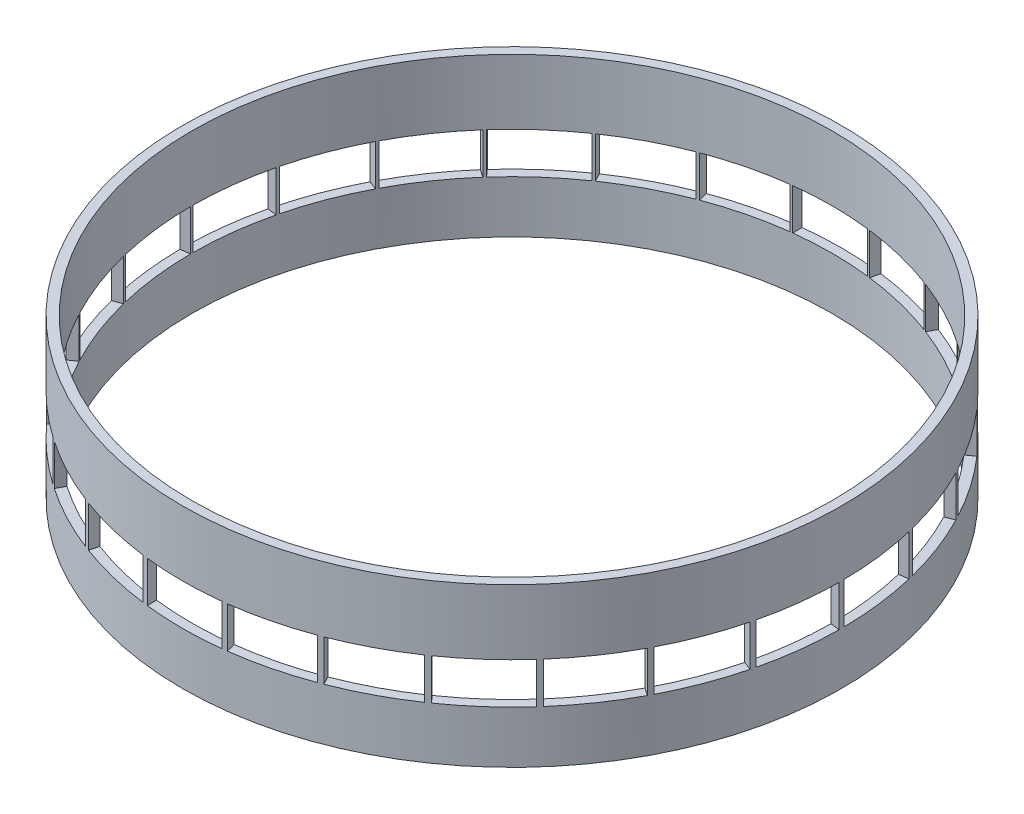
from build123d import *

# Parameters (mm, degrees)
SKETCH1_R           = 88.365
SKETCH1_R_2         = 85.865
BOSS_EXTRUDE1_DEPTH = 42.425
SKETCH2_W           = 20
SKETCH2_H           = 11
CUT_EXTRUDE1_DEPTH  = 89.365
CIRPATTERN1_COUNT   = 13


with BuildPart() as part:
    # Sketch1 → Boss-Extrude1 (new body)
    with BuildSketch(Plane(origin=(0, 0, 0), x_dir=(1, 0, 0), z_dir=(0, 1, 0))):
        Circle(SKETCH1_R)
        Circle(SKETCH1_R_2, mode=Mode.SUBTRACT)
    extrude(amount=BOSS_EXTRUDE1_DEPTH)

    # Sketch2 → Cut-Extrude1 (cut, symmetric)
    with BuildSketch(Plane.XY):
        with Locations((0, 19.5)):
            Rectangle(SKETCH2_W, SKETCH2_H)
    cut_extrude1 = extrude(amount=CUT_EXTRUDE1_DEPTH, both=True, mode=Mode.SUBTRACT)

    # CirPattern1: Cut-Extrude1 ×13 about axis
    cirpattern1_axis = Axis((0, 0, 0), (0, 1, 0))
    for i in range(1, CIRPATTERN1_COUNT):
        add(cut_extrude1.rotate(cirpattern1_axis, i * 360 / CIRPATTERN1_COUNT), mode=Mode.SUBTRACT)


solid = part.part
